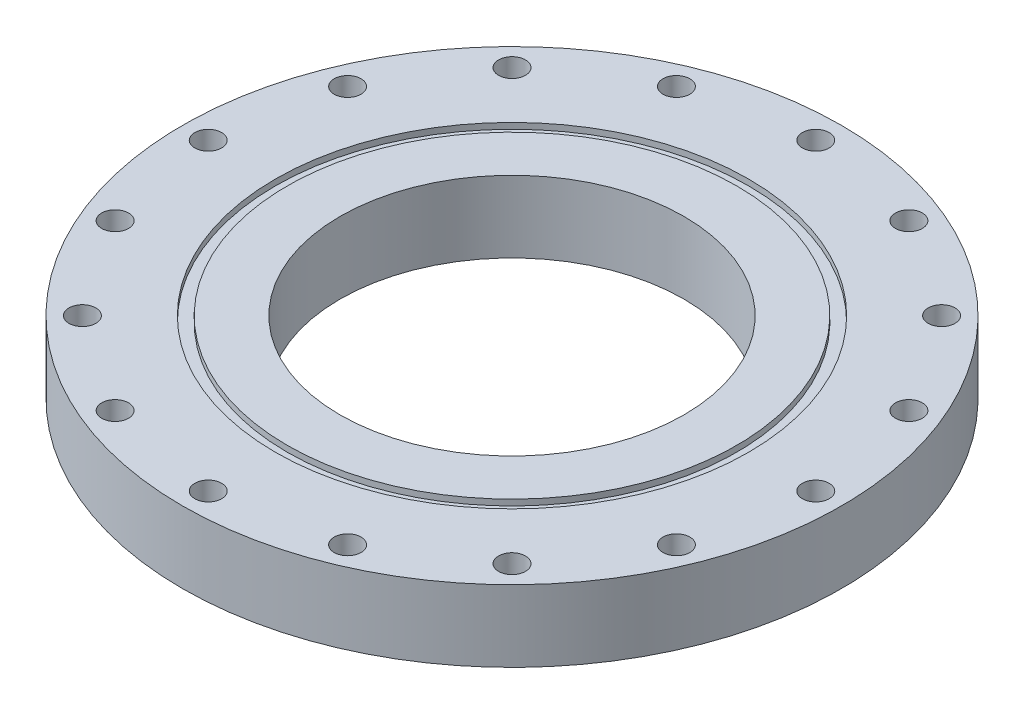
from build123d import *

# Parameters (mm, degrees)
SKETCH1_R           = 73.025
SKETCH1_R_2         = 38.1
BOSS_EXTRUDE1_DEPTH = 15.875
SKETCH2_R           = 2.97688
CUT_EXTRUDE1_DEPTH  = 16.875
CIRPATTERN1_COUNT   = 16
SKETCH3_R           = 52.4383
SKETCH3_R_2         = 49.7967
CUT_EXTRUDE2_DEPTH  = 1.3208


with BuildPart() as part:
    # Sketch1 → Boss-Extrude1 (new body)
    with BuildSketch(Plane(origin=(0, 0, 0), x_dir=(1, 0, 0), z_dir=(0, 1, 0))):
        Circle(SKETCH1_R)
        Circle(SKETCH1_R_2, mode=Mode.SUBTRACT)
    extrude(amount=BOSS_EXTRUDE1_DEPTH)

    # Sketch2 → Cut-Extrude1 (cut, through all)
    with BuildSketch(Plane(origin=(0, 15.875, 0), x_dir=(1, 0, 0), z_dir=(0, 1, 0))):
        with Locations((67.31, 0)):
            Circle(SKETCH2_R)
    cut_extrude1 = extrude(amount=-CUT_EXTRUDE1_DEPTH, mode=Mode.SUBTRACT)

    # CirPattern1: Cut-Extrude1 ×16 about axis
    cirpattern1_axis = Axis((0, 0, 0), (0, 1, 0))
    for i in range(1, CIRPATTERN1_COUNT):
        add(cut_extrude1.rotate(cirpattern1_axis, i * 360 / CIRPATTERN1_COUNT), mode=Mode.SUBTRACT)

    # Sketch3 → Cut-Extrude2 (cut)
    with BuildSketch(Plane(origin=(0, 15.875, 0), x_dir=(1, 0, 0), z_dir=(0, 1, 0))):
        Circle(SKETCH3_R)
        Circle(SKETCH3_R_2, mode=Mode.SUBTRACT)
    extrude(amount=-CUT_EXTRUDE2_DEPTH, mode=Mode.SUBTRACT)


solid = part.part
